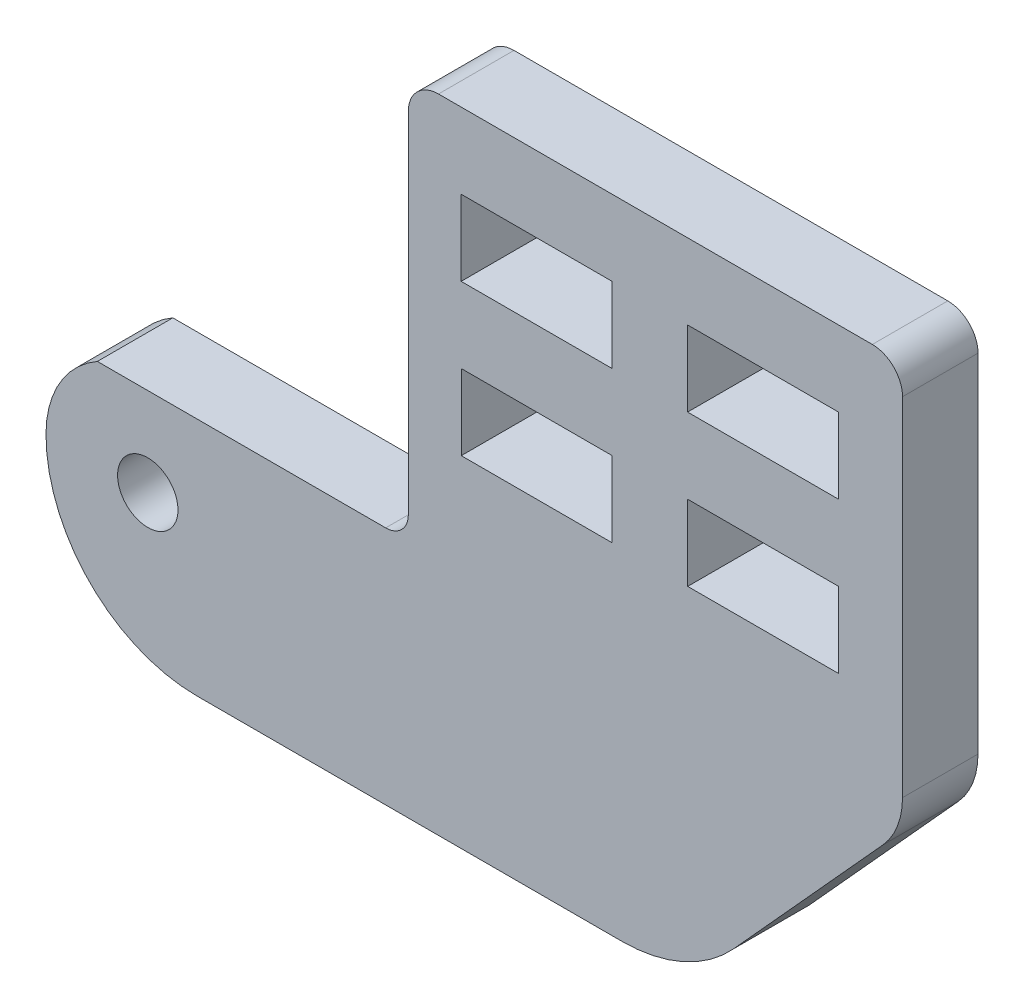
from build123d import *

# Parameters (mm, degrees)
SKETCH1_R           = 2
SKETCH1_W           = 10
SKETCH1_H           = 5
BOSS_EXTRUDE1_DEPTH = 5


with BuildPart() as part:
    # Sketch1 → Boss-Extrude1 (new body)
    with BuildSketch(Plane.XY):
        with BuildLine():
            Line((-1.742019887, -10.039309555), (26.411625907, -10.039309555))
            ThreePointArc((26.411625907, -10.039309555), (30.462414048, -9.182127251), (33.818749407, -6.757532642))
            Line((33.818749407, -6.757532642), (43.703561538, 4.140888457))
            ThreePointArc((43.703561538, 4.140888457), (44.664643865, 5.699695686), (44.999999787, 7.5))
            Line((44.999999787, 7.5), (44.999999787, 30.5))
            ThreePointArc((44.999999787, 30.5), (44.41421335, 31.914213562), (42.999999787, 32.5))
            Line((42.999999787, 32.5), (14.260362516, 32.5))
            ThreePointArc((14.260362516, 32.5), (12.846148953, 31.914213562), (12.260362516, 30.5))
            Line((12.260362516, 30.5), (12.260362516, 7.356217509))
            ThreePointArc((12.260362516, 7.356217509), (11.821022687, 6.295557338), (10.760362516, 5.856217509))
            Line((10.760362516, 5.856217509), (-8.340435128, 5.856217509))
            ThreePointArc((-8.340435128, 5.856217509), (-10.829871883, 3.386204984), (-11.741942625, 0))
            ThreePointArc((-11.741942625, 0), (-8.826972094, -7.096465655), (-1.742019887, -10.039309555))
        make_face()
        with Locations((-5, 0)):
            Circle(SKETCH1_R, mode=Mode.SUBTRACT)
        with Locations((20.760362516, 25)):
            Rectangle(SKETCH1_W, SKETCH1_H, mode=Mode.SUBTRACT)
        with Locations((35.760362516, 25)):
            Rectangle(SKETCH1_W, SKETCH1_H, mode=Mode.SUBTRACT)
        with Locations((20.768559845, 15.003110344)):
            Rectangle(SKETCH1_W, SKETCH1_H, mode=Mode.SUBTRACT)
        with Locations((35.768559845, 15.003110344)):
            Rectangle(SKETCH1_W, SKETCH1_H, mode=Mode.SUBTRACT)
    extrude(amount=BOSS_EXTRUDE1_DEPTH)


solid = part.part
